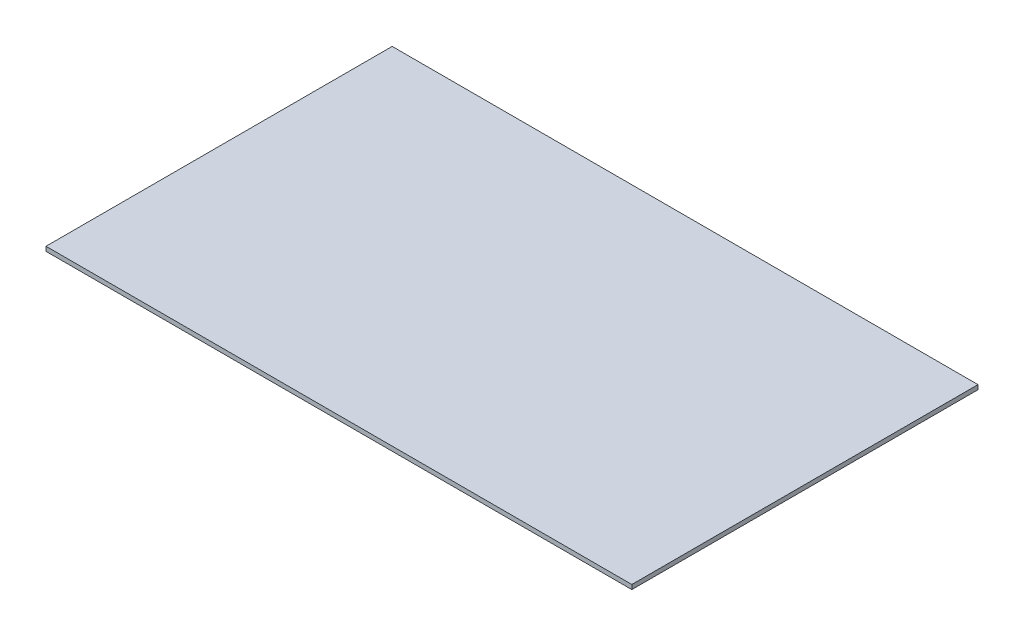
from build123d import *

# Parameters (mm, degrees)
SKETCH1_W           = 3352.8
SKETCH1_H           = 1981.2
BOSS_EXTRUDE1_DEPTH = 25.4


with BuildPart() as part:
    # Sketch1 → Boss-Extrude1 (new body)
    with BuildSketch(Plane(origin=(0, 0, 0), x_dir=(1, 0, 0), z_dir=(0, 1, 0))):
        with Locations((1676.4, -990.6)):
            Rectangle(SKETCH1_W, SKETCH1_H)
    extrude(amount=BOSS_EXTRUDE1_DEPTH)


solid = part.part
